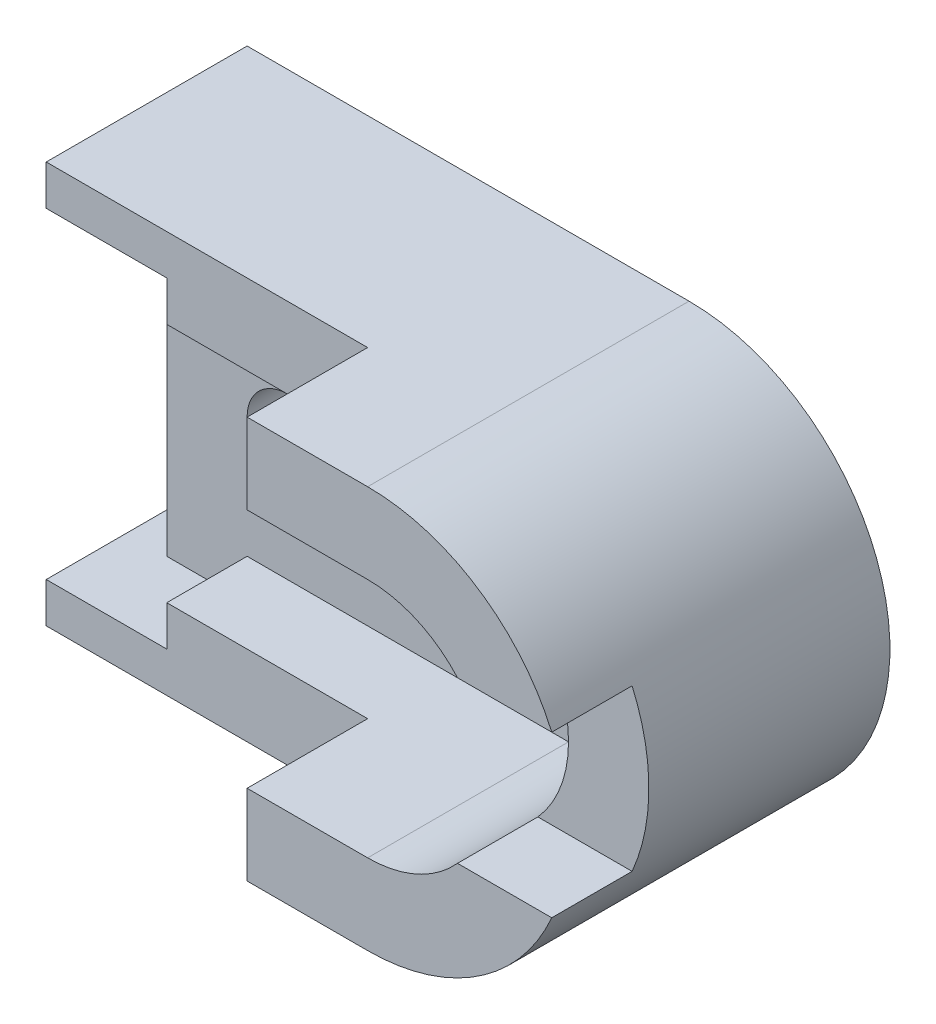
from build123d import *

# Parameters (mm, degrees)
BOSS_EXTRUDE1_DEPTH      = 50
BOSS_EXTRUDE2_DEPTH      = 30
BOSS_EXTRUDE3_DEPTH      = 50
BOSS_EXTRUDE7_DEPTH      = 50
BOSS_EXTRUDE7_DEPTH_BACK = 30
SKETCH5_W                = 20
SKETCH5_H                = 40
CUT_EXTRUDE1_DEPTH       = 211
CUT_EXTRUDE2_DEPTH       = 211
CUT_EXTRUDE3_DEPTH       = 211


with BuildPart() as part:
    # Sketch1 → Boss-Extrude1 (new body)
    with BuildSketch(Plane.XY):
        Polygon((0, 0), (-30, 0), (-30, 10), (50, 10), (50, -10), (0, -10), align=None)
    extrude(amount=BOSS_EXTRUDE1_DEPTH)

    # Sketch2 → Boss-Extrude2 (add)
    with BuildSketch(Plane(origin=(0, 0, 0), x_dir=(-1, 0, 0), z_dir=(0, 0, -1))):
        with BuildLine():
            Line((0, 0), (0, -10))
            Line((0, -10), (-50, -10))
            Line((-50, -10), (-80, -10))
            ThreePointArc((-80, -10), (-110, -40), (-80, -70))
            Line((-80, -70), (0, -70))
            Line((0, -70), (0, -80))
            Line((0, -80), (20, -80))
            Line((20, -80), (20, 0))
            Line((20, 0), (0, 0))
        make_face()
    extrude(amount=-BOSS_EXTRUDE2_DEPTH)

    # Sketch3 → Boss-Extrude3 (add)
    with BuildSketch(Plane(origin=(0, 0, 0), x_dir=(-1, 0, 0), z_dir=(0, 0, -1))):
        Polygon((0, -70), (0, -80), (30, -80), (30, -90), (-50, -90), (-50, -70), align=None)
    extrude(amount=-BOSS_EXTRUDE3_DEPTH)

    # Sketch4 → Boss-Extrude7 (add, two sides)
    with BuildSketch(Plane.XY.offset(30)) as boss_extrude7_sk:
        with BuildLine():
            Line((80, -90), (50, -90))
            Line((50, -90), (50, -70))
            Line((50, -70), (80, -70))
            ThreePointArc((80, -70), (110, -40), (80, -10))
            Line((80, -10), (50, -10))
            Line((50, -10), (50, 10))
            Line((50, 10), (80, 10))
            ThreePointArc((80, 10), (130, -40), (80, -90))
        make_face()
    extrude(amount=BOSS_EXTRUDE7_DEPTH)
    extrude(boss_extrude7_sk.sketch, amount=-BOSS_EXTRUDE7_DEPTH_BACK)

    # Sketch5 → Cut-Extrude1 (cut)
    with BuildSketch(Plane(origin=(0, 0, 0), x_dir=(0, 0, -1), z_dir=(1, 0, 0))):
        with Locations((-70, -40)):
            Rectangle(SKETCH5_W, SKETCH5_H)
    extrude(amount=CUT_EXTRUDE1_DEPTH, mode=Mode.SUBTRACT)

    # Sketch6 → Cut-Extrude2 (cut)
    with BuildSketch(Plane.XY.offset(30)):
        with BuildLine():
            Line((10, -30), (20, -30))
            ThreePointArc((20, -30), (30, -40), (20, -50))
            Line((20, -50), (10, -50))
            ThreePointArc((10, -50), (0, -40), (10, -30))
        make_face()
    extrude(amount=-CUT_EXTRUDE2_DEPTH, mode=Mode.SUBTRACT)

    # Sketch7 → Cut-Extrude3 (cut)
    with BuildSketch(Plane.XY.offset(30)):
        with BuildLine():
            Line((70, -30), (60, -30))
            ThreePointArc((60, -30), (50, -40), (60, -50))
            Line((60, -50), (70, -50))
            ThreePointArc((70, -50), (80, -40), (70, -30))
        make_face()
    extrude(amount=-CUT_EXTRUDE3_DEPTH, mode=Mode.SUBTRACT)


solid = part.part
